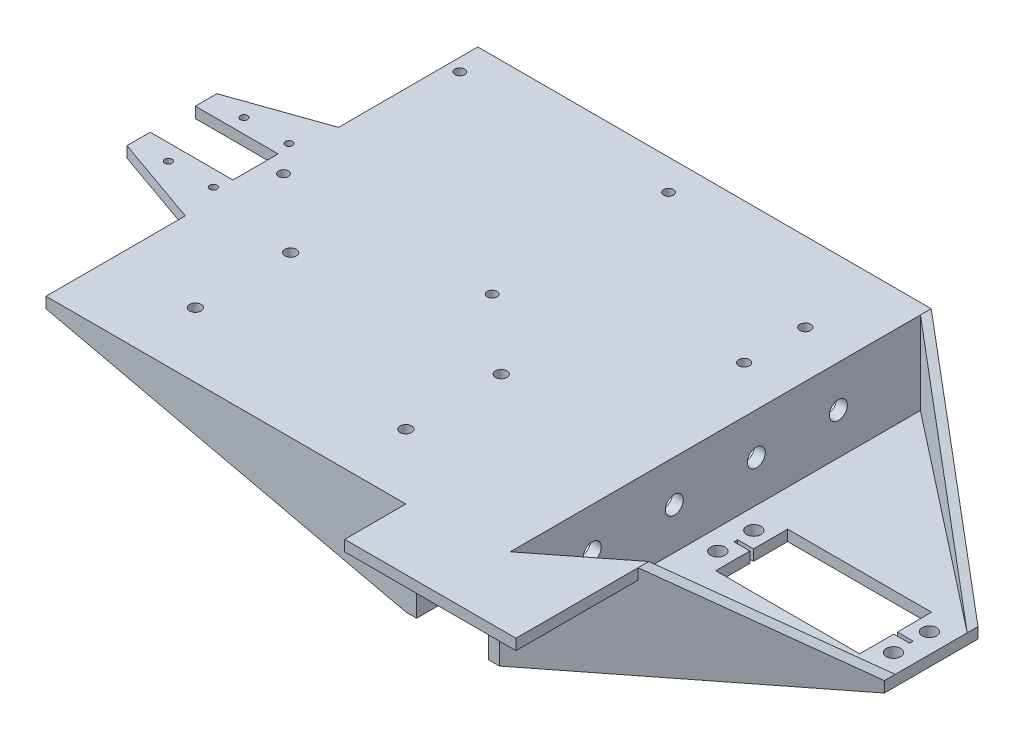
from build123d import *

# Parameters (mm, degrees)
BOSS_EXTRUDE1_DEPTH     = 120
SKETCH2_W               = 13
SKETCH2_H               = 10.628318584
BOSS_EXTRUDE2_DEPTH     = 3
BOSS_EXTRUDE3_DEPTH     = 3
SKETCH5_R               = 1.35
CUT_EXTRUDE1_DEPTH      = 10
SKETCH6_R               = 1
BOSS_EXTRUDE4_DEPTH     = 3
SKETCH7_W               = 2
SKETCH7_H               = 12.544695334
BOSS_EXTRUDE5_DEPTH     = 3
SKETCH8_R               = 1.6
CUT_EXTRUDE2_DEPTH      = 22
SKETCH9_R               = 2.5
CUT_EXTRUDE3_DEPTH      = 100
SKETCH10_R              = 2
CUT_EXTRUDE5_DEPTH      = 100
BOSS_EXTRUDE8_DEPTH     = 3
BOSS_EXTRUDE9_DEPTH     = 3
BOSS_EXTRUDE10_DEPTH    = 34
CUT_EXTRUDE6_DEPTH      = 145
CUT_EXTRUDE8_DEPTH      = 145
CUT_EXTRUDE8_DEPTH_BACK = 145
BOSS_EXTRUDE11_DEPTH    = 3
BOSS_EXTRUDE12_DEPTH    = 3
SKETCH21_W              = 4.5
SKETCH21_H              = 3
CUT_EXTRUDE9_DEPTH      = 10
CUT_EXTRUDE10_DEPTH     = 10
SKETCH26_W              = 114
SKETCH26_H              = 3
BOSS_EXTRUDE13_DEPTH    = 100
BOSS_EXTRUDE14_DEPTH    = 3
CUT_EXTRUDE11_DEPTH     = 3
SKETCH30_R              = 1
CUT_EXTRUDE12_DEPTH     = 3
CUT_EXTRUDE13_DEPTH     = 120
BOSS_EXTRUDE15_DEPTH    = 3
BOSS_EXTRUDE16_DEPTH    = 3
BOSS_EXTRUDE17_DEPTH    = 3
BOSS_EXTRUDE18_DEPTH    = 3
CUT_EXTRUDE14_DEPTH     = 120
BOSS_EXTRUDE19_DEPTH    = 10
BOSS_EXTRUDE20_DEPTH    = 23
CUT_EXTRUDE15_DEPTH     = 69
BOSS_EXTRUDE21_DEPTH    = 3
SKETCH43_W              = 2
SKETCH43_H              = 3
BOSS_EXTRUDE22_DEPTH    = 17
SKETCH44_W              = 45.6
SKETCH44_H              = 3
BOSS_EXTRUDE23_DEPTH    = 1.8


with BuildPart() as part:
    # Sketch1 → Boss-Extrude1 (new body)
    with BuildSketch(Plane.XY):
        Polygon((0, 0), (20, 0), (20, -23), (83, -23), (83, -20), (23, -20), (23, 3), (-3, 3), (-3, -20), (-103, -20), (-103, -23), (0, -23), align=None)
    extrude(amount=BOSS_EXTRUDE1_DEPTH)

    # Sketch2 → Boss-Extrude2 (add)
    with BuildSketch(Plane(origin=(0, 0, 0), x_dir=(-1, 0, 0), z_dir=(0, 0, -1))):
        with Locations((-3.5, 8.314159292)):
            Rectangle(SKETCH2_W, SKETCH2_H)
        Polygon((-23, 3), (-10, 3), (-10, 13.628318584), (-18.398230088, 13.628318584), (-83, -20), (-23, -20), align=None)
        Polygon((3, 13.628318584), (3, 3), (3, -20), (103, -20), align=None)
    extrude(amount=-BOSS_EXTRUDE2_DEPTH)

    # Sketch4 → Boss-Extrude3 (add)
    with BuildSketch(Plane.XY.offset(120)):
        Polygon((83, -20), (23, -20), (23, 3), (-3, 3), (-3, -20), (-103, -20), (-3, 13.628318584), (18.398230088, 13.628318584), align=None)
    extrude(amount=-BOSS_EXTRUDE3_DEPTH)

    # Sketch5 → Cut-Extrude1 (cut)
    with BuildSketch(Plane(origin=(0, -20, 0), x_dir=(1, 0, 0), z_dir=(0, 1, 0))):
        with Locations(Location((-99.5, -57.5, 0), (0, 0, 270))):
            Circle(SKETCH5_R)
        with Locations(Location((-99.5, -8.5, 0), (0, 0, 270))):
            Circle(SKETCH5_R)
        with Locations(Location((-41.5, -8.5, 0), (0, 0, 270))):
            Circle(SKETCH5_R)
        with Locations(Location((-41.5, -57.5, 0), (0, 0, 270))):
            Circle(SKETCH5_R)
    extrude(amount=-CUT_EXTRUDE1_DEPTH, mode=Mode.SUBTRACT)

    # Sketch6 → Boss-Extrude4 (add)
    with BuildSketch(Plane(origin=(0, -20, 0), x_dir=(1, 0, 0), z_dir=(0, 1, 0))):
        Polygon((-103, -53.5), (-103, -38.704545455), (-128, -49.5), (-128, -53.5), align=None)
        with Locations(Location((-118.5, -49.5, 0), (0, 0, 270))):
            Circle(SKETCH6_R, mode=Mode.SUBTRACT)
        with Locations(Location((-106, -49.5, 0), (0, 0, 270))):
            Circle(SKETCH6_R, mode=Mode.SUBTRACT)
        Polygon((-103, -66.044695334), (-128, -66.044695334), (-128, -70.5), (-103, -81.295454545), align=None)
        with Locations(Location((-118.5, -70.5, 0), (0, 0, 270))):
            Circle(SKETCH6_R, mode=Mode.SUBTRACT)
        with Locations(Location((-106, -70.5, 0), (0, 0, 270))):
            Circle(SKETCH6_R, mode=Mode.SUBTRACT)
    extrude(amount=-BOSS_EXTRUDE4_DEPTH)

    # Sketch7 → Boss-Extrude5 (add)
    with BuildSketch(Plane(origin=(0, -23, 0), x_dir=(-1, 0, 0), z_dir=(0, -1, 0))):
        with Locations((104, -59.772347667)):
            Rectangle(SKETCH7_W, SKETCH7_H)
    extrude(amount=-BOSS_EXTRUDE5_DEPTH)

    # Sketch8 → Cut-Extrude2 (cut)
    with BuildSketch(Plane(origin=(0, -20, 0), x_dir=(1, 0, 0), z_dir=(0, 1, 0))):
        with BuildLine():
            ThreePointArc((-22.6, -75.5), (-22.13137085, -76.63137085), (-21, -77.1))
            Line((-21, -77.1), (-21, -75.5))
            Line((-21, -75.5), (-22.6, -75.5))
        make_face()
        with BuildLine():
            Line((-21, -75.5), (-21, -77.1))
            ThreePointArc((-21, -77.1), (-19.86862915, -76.63137085), (-19.4, -75.5))
            ThreePointArc((-19.4, -75.5), (-21, -73.9), (-22.6, -75.5))
            Line((-22.6, -75.5), (-21, -75.5))
        make_face()
        with BuildLine():
            ThreePointArc((-21, -100.4), (-22.6, -102), (-21, -103.6))
            Line((-21, -103.6), (-21, -102))
            Line((-21, -102), (-21, -100.4))
        make_face()
        with BuildLine():
            Line((-21, -102), (-21, -103.6))
            ThreePointArc((-21, -103.6), (-19.86862915, -103.13137085), (-19.4, -102))
            ThreePointArc((-19.4, -102), (-19.86862915, -100.86862915), (-21, -100.4))
            Line((-21, -100.4), (-21, -102))
        make_face()
        with BuildLine():
            ThreePointArc((-79.5, -77.1), (-78.36862915, -76.63137085), (-77.9, -75.5))
            Line((-77.9, -75.5), (-79.5, -75.5))
            Line((-79.5, -75.5), (-79.5, -77.1))
        make_face()
        with BuildLine():
            Line((-79.5, -75.5), (-77.9, -75.5))
            ThreePointArc((-77.9, -75.5), (-80.63137085, -74.36862915), (-79.5, -77.1))
            Line((-79.5, -77.1), (-79.5, -75.5))
        make_face()
        with Locations(Location((-79.5, -102, 0), (0, 0, 270))):
            Circle(SKETCH8_R)
    extrude(amount=-CUT_EXTRUDE2_DEPTH, mode=Mode.SUBTRACT)

    # Sketch9 → Cut-Extrude3 (cut)
    with BuildSketch(Plane.ZY.offset(3)):
        with Locations((25.8, -8.5)):
            Circle(SKETCH9_R)
        with Locations((48.6, -8.5)):
            Circle(SKETCH9_R)
        with Locations((71.4, -8.5)):
            Circle(SKETCH9_R)
        with Locations((94.2, -8.5)):
            Circle(SKETCH9_R)
    extrude(amount=-CUT_EXTRUDE3_DEPTH, mode=Mode.SUBTRACT)

    # Sketch10 → Cut-Extrude5 (cut)
    with BuildSketch(Plane(origin=(0, -20, 0), x_dir=(1, 0, 0), z_dir=(0, 1, 0))):
        with Locations(Location((28.7, -65, 0), (0, 0, 270))):
            Circle(SKETCH10_R)
        Polygon((33.1, -50), (33.1, -59.5), (28.7, -59.5), (28.7, -60.5), (33.1, -60.5), (33.1, -70), (73.1, -70), (73.1, -60.5), (77.5, -60.5), (77.5, -59.5), (73.1, -59.5), (73.1, -50), align=None)
        with Locations(Location((28.7, -55, 0), (0, 0, 270))):
            Circle(SKETCH10_R)
        with Locations(Location((77.5, -65, 0), (0, 0, 270))):
            Circle(SKETCH10_R)
        with Locations(Location((77.5, -55, 0), (0, 0, 270))):
            Circle(SKETCH10_R)
    extrude(amount=-CUT_EXTRUDE5_DEPTH, mode=Mode.SUBTRACT)

    # Sketch14 → Boss-Extrude8 (add)
    with BuildSketch(Plane.XY.offset(3)):
        Polygon((23, 13.628318584), (23, 11.232876712), (83, -20), align=None)
        Polygon((18.398230088, 13.628318584), (23, 11.232876712), (23, 13.628318584), align=None)
    extrude(amount=-BOSS_EXTRUDE8_DEPTH)

    # Sketch15 → Boss-Extrude9 (add)
    with BuildSketch(Plane(origin=(0, 0, 117), x_dir=(-1, 0, 0), z_dir=(0, 0, -1))):
        Polygon((-83, -20), (-23, 11.232876712), (-23, 13.628318584), align=None)
        Polygon((-23, 13.628318584), (-23, 11.232876712), (-18.398230088, 13.628318584), align=None)
    extrude(amount=-BOSS_EXTRUDE9_DEPTH)

    # Sketch16 → Boss-Extrude10 (add)
    with BuildSketch(Plane(origin=(0, -20, 0), x_dir=(1, 0, 0), z_dir=(0, 1, 0))):
        Polygon((23, -117), (83, -70), (83, -73), (23, -120), align=None)
        Polygon((23, 0), (23, -3), (83, -50), (83, -47), align=None)
    extrude(amount=BOSS_EXTRUDE10_DEPTH)

    # Sketch17 → Cut-Extrude6 (cut)
    with BuildSketch(Plane.XY.offset(120)):
        Polygon((23, 13.628318584), (23, 14), (83, 14), (83, -20), align=None)
    extrude(amount=-CUT_EXTRUDE6_DEPTH, mode=Mode.SUBTRACT)

    # Sketch18 → Cut-Extrude8 (cut, two sides)
    with BuildSketch(Plane(origin=(0, -20, 0), x_dir=(1, 0, 0), z_dir=(0, 1, 0))) as cut_extrude8_sk:
        Polygon((83, -73), (23, -120), (83, -120), align=None)
        Polygon((83, -47), (23, 0), (83, 0), align=None)
    extrude(amount=CUT_EXTRUDE8_DEPTH, mode=Mode.SUBTRACT)
    extrude(cut_extrude8_sk.sketch, amount=-CUT_EXTRUDE8_DEPTH_BACK, mode=Mode.SUBTRACT)

    # Sketch19 → Boss-Extrude11 (add)
    with BuildSketch(Plane(origin=(0, -23, 0), x_dir=(-1, 0, 0), z_dir=(0, -1, 0))):
        Polygon((128, -49.5), (128, -47.5), (103, -38.704545455), align=None)
    extrude(amount=-BOSS_EXTRUDE11_DEPTH)

    # Sketch20 → Boss-Extrude12 (add)
    with BuildSketch(Plane(origin=(0, -23, 0), x_dir=(-1, 0, 0), z_dir=(0, -1, 0))):
        Polygon((128, -70.5), (128, -72.5), (103, -81.295454545), align=None)
    extrude(amount=-BOSS_EXTRUDE12_DEPTH)

    # Sketch21 → Cut-Extrude9 (cut)
    with BuildSketch(Plane(origin=(0, -20, 0), x_dir=(1, 0, 0), z_dir=(0, 1, 0))):
        with Locations((60.35, -77.5)):
            Rectangle(SKETCH21_W, SKETCH21_H)
        Polygon((58.1, -79), (58.1, -76), (53.6, -76), (53.6, -82), (62.6, -82), (62.6, -79), align=None)
    extrude(amount=-CUT_EXTRUDE9_DEPTH, mode=Mode.SUBTRACT)

    # Sketch24 → Cut-Extrude10 (cut)
    with BuildSketch(Plane(origin=(0, 3, 0), x_dir=(1, 0, 0), z_dir=(0, 1, 0))):
        with BuildLine():
            ThreePointArc((11.5, -22), (11.060660172, -20.939339828), (10, -20.5))
            Line((10, -20.5), (10, -22))
            Line((10, -22), (10, -23.5))
            ThreePointArc((10, -23.5), (11.060660172, -23.060660172), (11.5, -22))
        make_face()
        with BuildLine():
            Line((10, -22), (10, -20.5))
            ThreePointArc((10, -20.5), (8.5, -22), (10, -23.5))
            Line((10, -23.5), (10, -22))
        make_face()
        with BuildLine():
            ThreePointArc((11.5, -39), (11.060660172, -37.939339828), (10, -37.5))
            Line((10, -37.5), (10, -39))
            Line((10, -39), (10, -40.5))
            ThreePointArc((10, -40.5), (11.060660172, -40.060660172), (11.5, -39))
        make_face()
        with BuildLine():
            Line((10, -39), (10, -37.5))
            ThreePointArc((10, -37.5), (8.5, -39), (10, -40.5))
            Line((10, -40.5), (10, -39))
        make_face()
    extrude(amount=-CUT_EXTRUDE10_DEPTH, mode=Mode.SUBTRACT)

    # Sketch26 → Boss-Extrude13 (add)
    with BuildSketch(Plane.ZY.offset(3)):
        with Locations((60, 1.5)):
            Rectangle(SKETCH26_W, SKETCH26_H)
    extrude(amount=BOSS_EXTRUDE13_DEPTH)

    # Sketch27 → Boss-Extrude14 (add)
    with BuildSketch(Plane(origin=(0, 3, 0), x_dir=(1, 0, 0), z_dir=(0, 1, 0))):
        Polygon((-103, -38.704545455), (-128, -47.5), (-128, -53.5), (-105, -53.5), (-105, -66.044695334), (-128, -66.044695334), (-128, -72.5), (-103, -81.295454545), align=None)
    extrude(amount=-BOSS_EXTRUDE14_DEPTH)

    # Sketch29 → Cut-Extrude11 (cut)
    with BuildSketch(Plane(origin=(0, 0, 0), x_dir=(-1, 0, 0), z_dir=(0, -1, 0))):
        with BuildLine():
            ThreePointArc((100.85, -8.5), (99.5, -7.15), (98.15, -8.5))
            Line((98.15, -8.5), (99.5, -8.5))
            Line((99.5, -8.5), (99.5, -9.85))
            ThreePointArc((99.5, -9.85), (100.454594155, -9.454594155), (100.85, -8.5))
        make_face()
        with BuildLine():
            Line((99.5, -8.5), (98.15, -8.5))
            ThreePointArc((98.15, -8.5), (98.545405845, -9.454594155), (99.5, -9.85))
            Line((99.5, -9.85), (99.5, -8.5))
        make_face()
        with BuildLine():
            ThreePointArc((100.85, -57.5), (100.454594155, -56.545405845), (99.5, -56.15))
            Line((99.5, -56.15), (99.5, -57.5))
            Line((99.5, -57.5), (98.15, -57.5))
            ThreePointArc((98.15, -57.5), (99.5, -58.85), (100.85, -57.5))
        make_face()
        with BuildLine():
            Line((99.5, -57.5), (99.5, -56.15))
            ThreePointArc((99.5, -56.15), (98.545405845, -56.545405845), (98.15, -57.5))
            Line((98.15, -57.5), (99.5, -57.5))
        make_face()
        with BuildLine():
            ThreePointArc((42.85, -57.5), (42.454594155, -56.545405845), (41.5, -56.15))
            Line((41.5, -56.15), (41.5, -57.5))
            Line((41.5, -57.5), (42.85, -57.5))
        make_face()
        with BuildLine():
            Line((41.5, -57.5), (41.5, -56.15))
            ThreePointArc((41.5, -56.15), (40.545405845, -58.454594155), (42.85, -57.5))
            Line((42.85, -57.5), (41.5, -57.5))
        make_face()
        with BuildLine():
            ThreePointArc((41.5, -9.85), (42.454594155, -9.454594155), (42.85, -8.5))
            Line((42.85, -8.5), (41.5, -8.5))
            Line((41.5, -8.5), (41.5, -9.85))
        make_face()
        with BuildLine():
            Line((41.5, -8.5), (42.85, -8.5))
            ThreePointArc((42.85, -8.5), (40.545405845, -7.545405845), (41.5, -9.85))
            Line((41.5, -9.85), (41.5, -8.5))
        make_face()
        with BuildLine():
            ThreePointArc((81.1, -102), (80.63137085, -100.86862915), (79.5, -100.4))
            Line((79.5, -100.4), (79.5, -102))
            Line((79.5, -102), (77.9, -102))
            ThreePointArc((77.9, -102), (79.5, -103.6), (81.1, -102))
        make_face()
        with BuildLine():
            Line((79.5, -102), (79.5, -100.4))
            ThreePointArc((79.5, -100.4), (78.36862915, -100.86862915), (77.9, -102))
            Line((77.9, -102), (79.5, -102))
        make_face()
        with BuildLine():
            Line((77.9, -75.5), (79.5, -75.5))
            Line((79.5, -75.5), (79.5, -77.1))
            ThreePointArc((79.5, -77.1), (80.63137085, -76.63137085), (81.1, -75.5))
            ThreePointArc((81.1, -75.5), (79.5, -73.9), (77.9, -75.5))
        make_face()
        with BuildLine():
            Line((79.5, -77.1), (79.5, -75.5))
            Line((79.5, -75.5), (77.9, -75.5))
            ThreePointArc((77.9, -75.5), (78.36862915, -76.63137085), (79.5, -77.1))
        make_face()
        with BuildLine():
            ThreePointArc((21, -100.4), (19.86862915, -103.13137085), (22.6, -102))
            Line((22.6, -102), (21, -102))
            Line((21, -102), (21, -100.4))
        make_face()
        with BuildLine():
            Line((21, -102), (22.6, -102))
            ThreePointArc((22.6, -102), (22.13137085, -100.86862915), (21, -100.4))
            Line((21, -100.4), (21, -102))
        make_face()
        with BuildLine():
            ThreePointArc((21, -77.1), (22.13137085, -76.63137085), (22.6, -75.5))
            Line((22.6, -75.5), (21, -75.5))
            Line((21, -75.5), (21, -77.1))
        make_face()
        with BuildLine():
            Line((21, -75.5), (22.6, -75.5))
            ThreePointArc((22.6, -75.5), (19.86862915, -74.36862915), (21, -77.1))
            Line((21, -77.1), (21, -75.5))
        make_face()
    extrude(amount=-CUT_EXTRUDE11_DEPTH, mode=Mode.SUBTRACT)

    # Sketch30 → Cut-Extrude12 (cut)
    with BuildSketch(Plane(origin=(0, 0, 0), x_dir=(-1, 0, 0), z_dir=(0, -1, 0))):
        with Locations(Location((118.5, -70.5, 0), (0, 0, 270))):
            Circle(SKETCH30_R)
        with Locations(Location((106, -70.5, 0), (0, 0, 270))):
            Circle(SKETCH30_R)
        with Locations(Location((106, -49.5, 0), (0, 0, 270))):
            Circle(SKETCH30_R)
        with Locations(Location((118.5, -49.5, 0), (0, 0, 270))):
            Circle(SKETCH30_R)
    extrude(amount=-CUT_EXTRUDE12_DEPTH, mode=Mode.SUBTRACT)

    # Sketch31 → Cut-Extrude13 (cut)
    with BuildSketch(Plane.XY.offset(120)):
        Polygon((-3, 0), (-43.526315789, 0), (-103, -20), (-103, -23), (-3, -23), align=None)
        Polygon((-103, -20), (-43.526315789, 0), (-128, -20), (-128, -23), (-103, -23), align=None)
    extrude(amount=-CUT_EXTRUDE13_DEPTH, mode=Mode.SUBTRACT)

    # Sketch32 → Boss-Extrude15 (add)
    with BuildSketch(Plane.XY.offset(117)):
        Polygon((-3, 0), (-103, 0), (-103, 3), (-3, 13.628318584), align=None)
    extrude(amount=BOSS_EXTRUDE15_DEPTH)

    # Sketch33 → Boss-Extrude16 (add)
    with BuildSketch(Plane(origin=(0, 0, 3), x_dir=(-1, 0, 0), z_dir=(0, 0, -1))):
        Polygon((3, 0), (3, 13.628318584), (103, 3), (103, 0), align=None)
    extrude(amount=BOSS_EXTRUDE16_DEPTH)

    # Sketch34 → Boss-Extrude17 (add)
    with BuildSketch(Plane(origin=(0, 0, 0), x_dir=(-1, 0, 0), z_dir=(0, 0, -1))):
        Polygon((103, 0), (3, -23), (3, 0), align=None)
    extrude(amount=-BOSS_EXTRUDE17_DEPTH)

    # Sketch35 → Boss-Extrude18 (add)
    with BuildSketch(Plane.XY.offset(120)):
        Polygon((-3, -23), (-103, 0), (-3, 0), align=None)
    extrude(amount=-BOSS_EXTRUDE18_DEPTH)

    # Sketch36 → Cut-Extrude14 (cut)
    with BuildSketch(Plane(origin=(0, 0, 0), x_dir=(-1, 0, 0), z_dir=(0, 0, -1))):
        Polygon((-23, 3), (103, 3), (3, 13.628318584), (-23, 13.628318584), align=None)
        Polygon((-41.963157895, 3), (-23, 3), (-23, 13.628318584), align=None)
        Polygon((-83, -20), (-23, 3), (-41.963157895, 3), align=None)
    extrude(amount=-CUT_EXTRUDE14_DEPTH, mode=Mode.SUBTRACT)

    # Sketch37 → Boss-Extrude19 (add)
    with BuildSketch(Plane(origin=(0, 3, 0), x_dir=(1, 0, 0), z_dir=(0, 1, 0))):
        Polygon((23, -120), (44.6, -103.08), (44.6, -100.08), (23, -117), align=None)
    extrude(amount=-BOSS_EXTRUDE19_DEPTH)

    # Sketch38 → Boss-Extrude20 (add)
    with BuildSketch(Plane(origin=(0, 3, 0), x_dir=(1, 0, 0), z_dir=(0, 1, 0))):
        Polygon((83, -73), (44.6, -103.08), (44.6, -100.08), (83, -70), align=None)
    extrude(amount=-BOSS_EXTRUDE20_DEPTH)

    # Sketch41 → Cut-Extrude15 (cut)
    with BuildSketch(Plane.XY.offset(120)):
        Polygon((84.974777816, -20), (84.974777816, 3), (44.6, 3), (83, -20), align=None)
    extrude(amount=-CUT_EXTRUDE15_DEPTH, mode=Mode.SUBTRACT)

    # Sketch42 → Boss-Extrude21 (add)
    with BuildSketch(Plane(origin=(0, 3, 0), x_dir=(1, 0, 0), z_dir=(0, 1, 0))):
        Polygon((44.6, -120), (23, -120), (-1, -120), (-1, -135.2), (44.6, -135.2), align=None)
        Polygon((23, -120), (44.6, -120), (44.6, -103.08), align=None)
    extrude(amount=-BOSS_EXTRUDE21_DEPTH)

    # Sketch43 → Boss-Extrude22 (add)
    with BuildSketch(Plane.XY.offset(120)):
        with Locations((-2, 1.5)):
            Rectangle(SKETCH43_W, SKETCH43_H)
    extrude(amount=BOSS_EXTRUDE22_DEPTH)

    # Sketch44 → Boss-Extrude23 (add)
    with BuildSketch(Plane.XY.offset(135.2)):
        with Locations((21.8, 1.5)):
            Rectangle(SKETCH44_W, SKETCH44_H)
    extrude(amount=BOSS_EXTRUDE23_DEPTH)


solid = part.part
